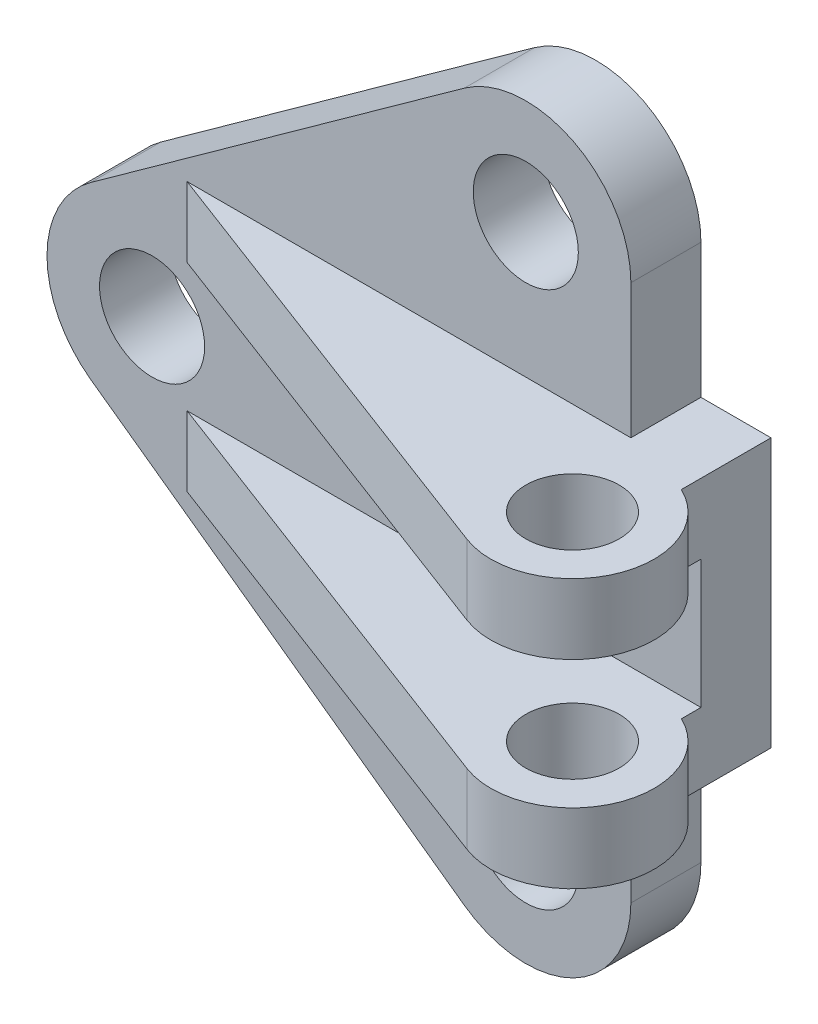
from build123d import *

# Parameters (mm, degrees)
SKETCH1_R            = 9
BOSS_EXTRUDE1_DEPTH  = 12
SKETCH6_W            = 12
SKETCH6_H            = 46
BOSS_EXTRUDE5_DEPTH  = 12
SKETCH7_R            = 8
BOSS_EXTRUDE17_DEPTH = 12


with BuildPart() as part:
    # Sketch1 → Boss-Extrude1 (new body)
    with BuildSketch(Plane.XY):
        with BuildLine():
            Line((-10.505448867, 14.616276684), (53.494551133, 60.616276684))
            ThreePointArc((53.494551133, 60.616276684), (72.212853353, 62.017148304), (82, 46))
            Line((82, 46), (82, -46))
            ThreePointArc((82, -46), (72.212853353, -62.017148304), (53.494551133, -60.616276684))
            Line((53.494551133, -60.616276684), (-10.505448867, -14.616276684))
            ThreePointArc((-10.505448867, -14.616276684), (-18, 0), (-10.505448867, 14.616276684))
        make_face()
        Circle(SKETCH1_R, mode=Mode.SUBTRACT)
        with Locations((64, 46)):
            Circle(SKETCH1_R, mode=Mode.SUBTRACT)
        with Locations((64, -46)):
            Circle(SKETCH1_R, mode=Mode.SUBTRACT)
    extrude(amount=BOSS_EXTRUDE1_DEPTH)

    # Sketch6 → Boss-Extrude5 (add)
    with BuildSketch(Plane(origin=(82, 0, 0), x_dir=(0, 0, -1), z_dir=(1, 0, 0))):
        with Locations((-6, 0)):
            Rectangle(SKETCH6_W, SKETCH6_H)
    extrude(amount=BOSS_EXTRUDE5_DEPTH)

    # Sketch7 → Boss-Extrude17 (add)
    with BuildSketch(Plane.XZ.offset(23)):
        with BuildLine():
            Line((6, 12), (94, 12))
            Line((94, 12), (94, 15.350889359))
            ThreePointArc((94, 15.350889359), (100.88398553, 33.477491841), (83.054187792, 41.097287567))
            Line((83.054187792, 41.097287567), (6, 12))
        make_face()
        with Locations((88, 28)):
            Circle(SKETCH7_R, mode=Mode.SUBTRACT)
    boss_extrude17 = extrude(amount=-BOSS_EXTRUDE17_DEPTH)

    # Mirror2: Boss-Extrude17 across plane
    add(boss_extrude17.mirror(Plane.ZX))


solid = part.part
